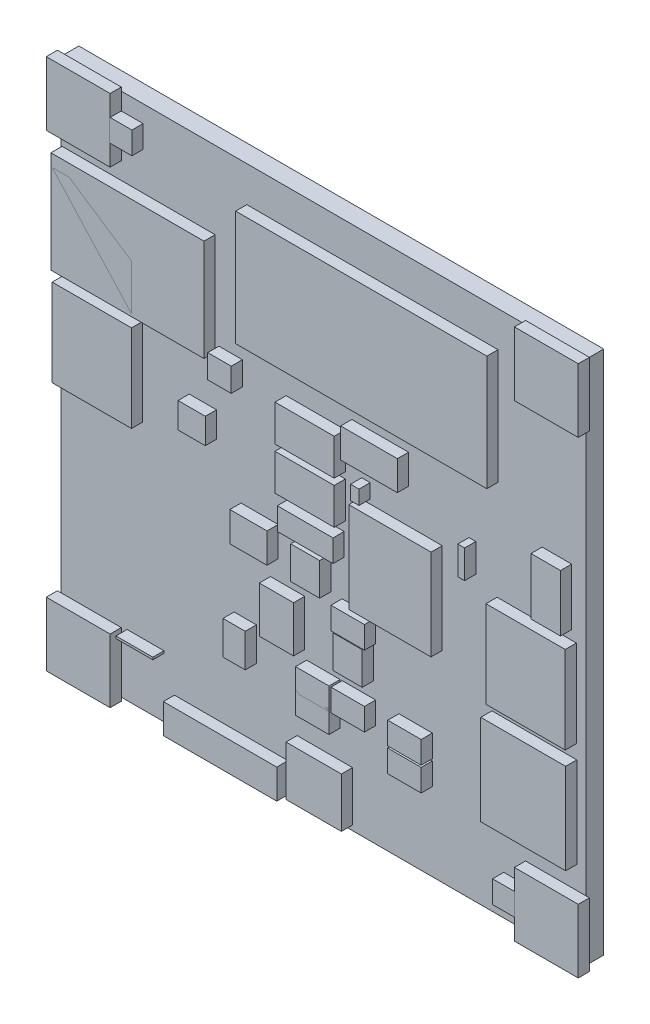
from build123d import *

# Parameters (mm, degrees)
SKETCH1_W                            = 46.99
SKETCH1_H                            = 46.99
BOARD_DEPTH                          = 1.6
SKETCH2_W                            = 3.327
SKETCH2_H                            = 2.6635
EXTRUDE_1210_1_DEPTH                 = 1
SKETCH3_W                            = 4.9968
SKETCH3_H                            = 1.9914
EXTRUDE_1206_1_DEPTH                 = 1
SKETCH4_W                            = 5.3016
SKETCH4_H                            = 3.2516
EIA3528_1_DEPTH                      = 1
SKETCH5_W                            = 5.3016
SKETCH5_H                            = 3.2516
EIA3528_2_DEPTH                      = 1
SKETCH6_W                            = 2.9968
SKETCH6_H                            = 1.9914
F_0603_CAP_1_DEPTH                   = 1
SKETCH7_W                            = 1.9914
SKETCH7_H                            = 2.9968
F_0603_CAP_2_DEPTH                   = 1
SKETCH8_W                            = 2.5908
SKETCH8_H                            = 2.921
SOT23_1_DEPTH                        = 1
SKETCH9_W                            = 2.5908
SKETCH9_H                            = 2.921
SOT23_2_DEPTH                        = 1
SKETCH10_W                           = 2
SKETCH10_H                           = 2
FIDUCIAL_1X2_1_DEPTH                 = 1
SKETCH11_W                           = 2
SKETCH11_H                           = 2
FIDUCIAL_1X2_2_DEPTH                 = 1
SKETCH14_W                           = 13.7016
SKETCH14_H                           = 9.1016
POWER_JACK_PTH_1_DEPTH               = 1
SKETCH15_W                           = 7.6016
SKETCH15_H                           = 8.1016
JST_2_SMD_1_DEPTH                    = 1
SKETCH16_W                           = 10.16
SKETCH16_H                           = 2.6416
EXTRUDE_1X04_1_DEPTH                 = 1
SKETCH17_W                           = 2.6416
SKETCH17_H                           = 5.08
EXTRUDE_1X02_1_DEPTH                 = 1
SKETCH18_W                           = 7.1016
SKETCH18_H                           = 7.8
SCREWTERMINAL_3_5MM_2_1_DEPTH        = 1
SKETCH19_W                           = 7.1016
SKETCH19_H                           = 7.8
SCREWTERMINAL_3_5MM_2_2_DEPTH        = 1
SKETCH20_W                           = 7.1016
SKETCH20_H                           = 7.8
SCREWTERMINAL_3_5MM_2_3_DEPTH        = 1
SKETCH21_W                           = 2.4384
SKETCH21_H                           = 2.286
SJ_2S_1_DEPTH                        = 1
SKETCH22_W                           = 2.1016
SKETCH22_H                           = 2.1115
SJ_2S_NO_1_DEPTH                     = 1
SKETCH23_W                           = 0.6096
SKETCH23_H                           = 2.54
PTH_JUMPER_NC_BOTTOM_NO_SILK_1_DEPTH = 1
SKETCH24_W                           = 5.08
SKETCH24_H                           = 2.6416
EXTRUDE_1X02_2_DEPTH                 = 1
SKETCH25_W                           = 7.3635
SKETCH25_H                           = 8.127
CR75_1_DEPTH                         = 1
SKETCH26_W                           = 22.49
SKETCH26_H                           = 10.28
SFE_LOGO_NAME_FLAME_2_1_DEPTH        = 1
SKETCH27_W                           = 4.9628
SKETCH27_H                           = 4.4514
OSHW_LOGO_M_1_DEPTH                  = 1
SKETCH28_W                           = 2.9776
SKETCH28_H                           = 2.6708
OSHW_LOGO_S_1_DEPTH                  = 1
SKETCH30_W                           = 0.7524
SKETCH30_H                           = 1.2762
EXTRUDE_0805_1_DEPTH                 = 1
SKETCH31_W                           = 2.9968
SKETCH31_H                           = 1.9914
F_0603_RES_1_DEPTH                   = 1
SKETCH32_W                           = 2.9968
SKETCH32_H                           = 1.9914
F_0603_RES_2_DEPTH                   = 1
SKETCH33_W                           = 2.9968
SKETCH33_H                           = 1.9914
F_0603_RES_3_DEPTH                   = 1
SKETCH34_W                           = 2.9968
SKETCH34_H                           = 1.9914
F_0603_RES_4_DEPTH                   = 1
SKETCH35_W                           = 2.9968
SKETCH35_H                           = 1.9914
F_0603_RES_5_DEPTH                   = 1
SKETCH36_W                           = 3.3016
SKETCH36_H                           = 0.2032
TRIMPOT_3MM_1_DEPTH                  = 1
SKETCH37_W                           = 5.715
SKETCH37_H                           = 5.715
STAND_OFF_1_DEPTH                    = 1
SKETCH38_W                           = 5.715
SKETCH38_H                           = 5.715
STAND_OFF_2_DEPTH                    = 1
SKETCH39_W                           = 5.715
SKETCH39_H                           = 5.715
STAND_OFF_3_DEPTH                    = 1
SKETCH40_W                           = 5.715
SKETCH40_H                           = 5.715
STAND_OFF_4_DEPTH                    = 1
SKETCH41_W                           = 3.0635
SKETCH41_H                           = 4.127
MSOP_12_GND_1_DEPTH                  = 1


with BuildPart() as part:
    # Sketch1 → BOARD (new body)
    with BuildSketch(Plane.XY):
        with Locations((23.495, 23.495)):
            Rectangle(SKETCH1_W, SKETCH1_H)
    extrude(amount=BOARD_DEPTH)


with BuildPart() as body_2:
    # Sketch2 → 1210-1 (new body)
    with BuildSketch(Plane.XY.offset(1.6)):
        with Locations((17.78, 19.08175)):
            Rectangle(SKETCH2_W, SKETCH2_H)
    extrude(amount=EXTRUDE_1210_1_DEPTH)


with BuildPart() as body_3:
    # Sketch3 → 1206-1 (new body)
    with BuildSketch(Plane.XY.offset(1.6)):
        with Locations((22.86, 21.8313)):
            Rectangle(SKETCH3_W, SKETCH3_H)
    extrude(amount=EXTRUDE_1206_1_DEPTH)


with BuildPart() as body_4:
    # Sketch4 → EIA3528-1 (new body)
    with BuildSketch(Plane.XY.offset(1.6)):
        with Locations((22.8092, 29.1342)):
            Rectangle(SKETCH4_W, SKETCH4_H)
    extrude(amount=EIA3528_1_DEPTH)


with BuildPart() as body_5:
    # Sketch5 → EIA3528-2 (new body)
    with BuildSketch(Plane.XY.offset(1.6)):
        with Locations((22.8092, 25.3242)):
            Rectangle(SKETCH5_W, SKETCH5_H)
    extrude(amount=EIA3528_2_DEPTH)


with BuildPart() as body_6:
    # Sketch6 → 0603-CAP-1 (new body)
    with BuildSketch(Plane.XY.offset(1.6)):
        with Locations((26.67, 16.5227)):
            Rectangle(SKETCH6_W, SKETCH6_H)
    extrude(amount=F_0603_CAP_1_DEPTH)


with BuildPart() as body_7:
    # Sketch7 → 0603-CAP-2 (new body)
    with BuildSketch(Plane.XY.offset(1.6)):
        with Locations((16.4973, 10.16)):
            Rectangle(SKETCH7_W, SKETCH7_H)
    extrude(amount=F_0603_CAP_2_DEPTH)


with BuildPart() as body_8:
    # Sketch8 → SOT23-1 (new body)
    with BuildSketch(Plane.XY.offset(1.6)):
        with Locations((22.86, 19.0119)):
            Rectangle(SKETCH8_W, SKETCH8_H)
    extrude(amount=SOT23_1_DEPTH)


with BuildPart() as body_9:
    # Sketch9 → SOT23-2 (new body)
    with BuildSketch(Plane.XY.offset(1.6)):
        with Locations((26.67, 14.0081)):
            Rectangle(SKETCH9_W, SKETCH9_H)
    extrude(amount=SOT23_2_DEPTH)


with BuildPart() as body_10:
    # Sketch10 → FIDUCIAL-1X2-1 (new body)
    with BuildSketch(Plane.XY.offset(1.6)):
        with Locations((6.35, 44.45)):
            Rectangle(SKETCH10_W, SKETCH10_H)
    extrude(amount=FIDUCIAL_1X2_1_DEPTH)


with BuildPart() as body_11:
    # Sketch11 → FIDUCIAL-1X2-2 (new body)
    with BuildSketch(Plane.XY.offset(1.6)):
        with Locations((40.64, 2.54)):
            Rectangle(SKETCH11_W, SKETCH11_H)
    extrude(amount=FIDUCIAL_1X2_2_DEPTH)


with BuildPart() as body_12:
    # Sketch14 → POWER_JACK_PTH-1 (new body)
    with BuildSketch(Plane.XY.offset(1.6)):
        with Locations((6.9508, 35.5092)):
            Rectangle(SKETCH14_W, SKETCH14_H)
    extrude(amount=POWER_JACK_PTH_1_DEPTH)


with BuildPart() as body_13:
    # Sketch15 → JST-2-SMD-1 (new body)
    with BuildSketch(Plane.XY.offset(1.6)):
        with Locations((42.3792, 11.4808)):
            Rectangle(SKETCH15_W, SKETCH15_H)
    extrude(amount=JST_2_SMD_1_DEPTH)


with BuildPart() as body_14:
    # Sketch16 → 1X04-1 (new body)
    with BuildSketch(Plane.XY.offset(1.6)):
        with Locations((15.24, 1.2192)):
            Rectangle(SKETCH16_W, SKETCH16_H)
    extrude(amount=EXTRUDE_1X04_1_DEPTH)


with BuildPart() as body_15:
    # Sketch17 → 1X02-1 (new body)
    with BuildSketch(Plane.XY.offset(1.6)):
        with Locations((44.3992, 27.94)):
            Rectangle(SKETCH17_W, SKETCH17_H)
    extrude(amount=EXTRUDE_1X02_1_DEPTH)


with BuildPart() as body_16:
    # Sketch18 → SCREWTERMINAL-3_5MM-2-1 (new body)
    with BuildSketch(Plane.XY.offset(1.6)):
        with Locations((42.5942, 20.673)):
            Rectangle(SKETCH18_W, SKETCH18_H)
    extrude(amount=SCREWTERMINAL_3_5MM_2_1_DEPTH)


with BuildPart() as body_17:
    # Sketch19 → SCREWTERMINAL-3_5MM-2-2 (new body)
    with BuildSketch(Plane.XY.offset(1.6)):
        with Locations((3.7608, 35.08)):
            Rectangle(SKETCH19_W, SKETCH19_H)
    extrude(amount=SCREWTERMINAL_3_5MM_2_2_DEPTH)


with BuildPart() as body_18:
    # Sketch20 → SCREWTERMINAL-3_5MM-2-3 (new body)
    with BuildSketch(Plane.XY.offset(1.6)):
        with Locations((3.7608, 26.19)):
            Rectangle(SKETCH20_W, SKETCH20_H)
    extrude(amount=SCREWTERMINAL_3_5MM_2_3_DEPTH)


with BuildPart() as body_19:
    # Sketch21 → SJ_2S-1 (new body)
    with BuildSketch(Plane.XY.offset(1.6)):
        with Locations((12.7, 25.4)):
            Rectangle(SKETCH21_W, SKETCH21_H)
    extrude(amount=SJ_2S_1_DEPTH)


with BuildPart() as body_20:
    # Sketch22 → SJ_2S-NO-1 (new body)
    with BuildSketch(Plane.XY.offset(1.6)):
        with Locations((15.1892, 30.5308)):
            Rectangle(SKETCH22_W, SKETCH22_H)
    extrude(amount=SJ_2S_NO_1_DEPTH)


with BuildPart() as body_21:
    # Sketch23 → PTH-JUMPER-NC_BOTTOM_NO_SILK-1 (new body)
    with BuildSketch(Plane.XY.offset(1.6)):
        with Locations((36.83, 26.67)):
            Rectangle(SKETCH23_W, SKETCH23_H)
    extrude(amount=PTH_JUMPER_NC_BOTTOM_NO_SILK_1_DEPTH)


with BuildPart() as body_22:
    # Sketch24 → 1X02-2 (new body)
    with BuildSketch(Plane.XY.offset(1.6)):
        with Locations((28.575, 30.5308)):
            Rectangle(SKETCH24_W, SKETCH24_H)
    extrude(amount=EXTRUDE_1X02_2_DEPTH)


with BuildPart() as body_23:
    # Sketch25 → CR75-1 (new body)
    with BuildSketch(Plane.XY.offset(1.6)):
        with Locations((30.44825, 22.05)):
            Rectangle(SKETCH25_W, SKETCH25_H)
    extrude(amount=CR75_1_DEPTH)


with BuildPart() as body_24:
    # Sketch26 → SFE_LOGO_NAME_FLAME__2-1 (new body)
    with BuildSketch(Plane.XY.offset(1.6)):
        with Locations((27.882, 38.668)):
            Rectangle(SKETCH26_W, SKETCH26_H)
    extrude(amount=SFE_LOGO_NAME_FLAME_2_1_DEPTH)


with BuildPart() as body_25:
    # Sketch27 → OSHW-LOGO-M-1 (new body)
    with BuildSketch(Plane.XY.offset(1.6)):
        with Locations((23.622, 2.6687)):
            Rectangle(SKETCH27_W, SKETCH27_H)
    extrude(amount=OSHW_LOGO_M_1_DEPTH)


with BuildPart() as body_26:
    # Sketch28 → OSHW-LOGO-S-1 (new body)
    with BuildSketch(Plane.XY):
        with Locations((2.54, 7.7734)):
            Rectangle(SKETCH28_W, SKETCH28_H)
    extrude(amount=-OSHW_LOGO_S_1_DEPTH)


with BuildPart() as body_27:
    # Sketch30 → 0805-1 (new body)
    with BuildSketch(Plane.XY.offset(1.6)):
        with Locations((27.305, 27.1399)):
            Rectangle(SKETCH30_W, SKETCH30_H)
    extrude(amount=EXTRUDE_0805_1_DEPTH)


with BuildPart() as body_28:
    # Sketch31 → 0603-RES-1 (new body)
    with BuildSketch(Plane.XY.offset(1.6)):
        with Locations((26.67, 10.1727)):
            Rectangle(SKETCH31_W, SKETCH31_H)
    extrude(amount=F_0603_RES_1_DEPTH)


with BuildPart() as body_29:
    # Sketch32 → 0603-RES-2 (new body)
    with BuildSketch(Plane.XY.offset(1.6)):
        with Locations((23.495, 8.3947)):
            Rectangle(SKETCH32_W, SKETCH32_H)
    extrude(amount=F_0603_RES_2_DEPTH)


with BuildPart() as body_30:
    # Sketch33 → 0603-RES-3 (new body)
    with BuildSketch(Plane.XY.offset(1.6)):
        with Locations((23.495, 10.1727)):
            Rectangle(SKETCH33_W, SKETCH33_H)
    extrude(amount=F_0603_RES_3_DEPTH)


with BuildPart() as body_31:
    # Sketch34 → 0603-RES-4 (new body)
    with BuildSketch(Plane.XY.offset(1.6)):
        with Locations((31.75, 10.1473)):
            Rectangle(SKETCH34_W, SKETCH34_H)
    extrude(amount=F_0603_RES_4_DEPTH)


with BuildPart() as body_32:
    # Sketch35 → 0603-RES-5 (new body)
    with BuildSketch(Plane.XY.offset(1.6)):
        with Locations((31.75, 7.9883)):
            Rectangle(SKETCH35_W, SKETCH35_H)
    extrude(amount=F_0603_RES_5_DEPTH)


with BuildPart() as body_33:
    # Sketch36 → TRIMPOT-3MM-1 (new body)
    with BuildSketch(Plane.XY.offset(1.6)):
        with Locations((7.5692, 5.41)):
            Rectangle(SKETCH36_W, SKETCH36_H)
    extrude(amount=TRIMPOT_3MM_1_DEPTH)


with BuildPart() as body_34:
    # Sketch37 → STAND-OFF-1 (new body)
    with BuildSketch(Plane.XY.offset(1.6)):
        with Locations((2.54, 2.54)):
            Rectangle(SKETCH37_W, SKETCH37_H)
    extrude(amount=STAND_OFF_1_DEPTH)


with BuildPart() as body_35:
    # Sketch38 → STAND-OFF-2 (new body)
    with BuildSketch(Plane.XY.offset(1.6)):
        with Locations((2.54, 44.45)):
            Rectangle(SKETCH38_W, SKETCH38_H)
    extrude(amount=STAND_OFF_2_DEPTH)


with BuildPart() as body_36:
    # Sketch39 → STAND-OFF-3 (new body)
    with BuildSketch(Plane.XY.offset(1.6)):
        with Locations((44.45, 44.45)):
            Rectangle(SKETCH39_W, SKETCH39_H)
    extrude(amount=STAND_OFF_3_DEPTH)


with BuildPart() as body_37:
    # Sketch40 → STAND-OFF-4 (new body)
    with BuildSketch(Plane.XY.offset(1.6)):
        with Locations((44.45, 2.54)):
            Rectangle(SKETCH40_W, SKETCH40_H)
    extrude(amount=STAND_OFF_4_DEPTH)


with BuildPart() as body_38:
    # Sketch41 → MSOP-12_GND-1 (new body)
    with BuildSketch(Plane.XY.offset(1.6)):
        with Locations((20.28825, 13.97)):
            Rectangle(SKETCH41_W, SKETCH41_H)
    extrude(amount=MSOP_12_GND_1_DEPTH)


solid = Compound([part.part, body_2.part, body_3.part, body_4.part, body_5.part, body_6.part, body_7.part, body_8.part, body_9.part, body_10.part, body_11.part, body_12.part, body_13.part, body_14.part, body_15.part, body_16.part, body_17.part, body_18.part, body_19.part, body_20.part, body_21.part, body_22.part, body_23.part, body_24.part, body_25.part, body_26.part, body_27.part, body_28.part, body_29.part, body_30.part, body_31.part, body_32.part, body_33.part, body_34.part, body_35.part, body_36.part, body_37.part, body_38.part])
